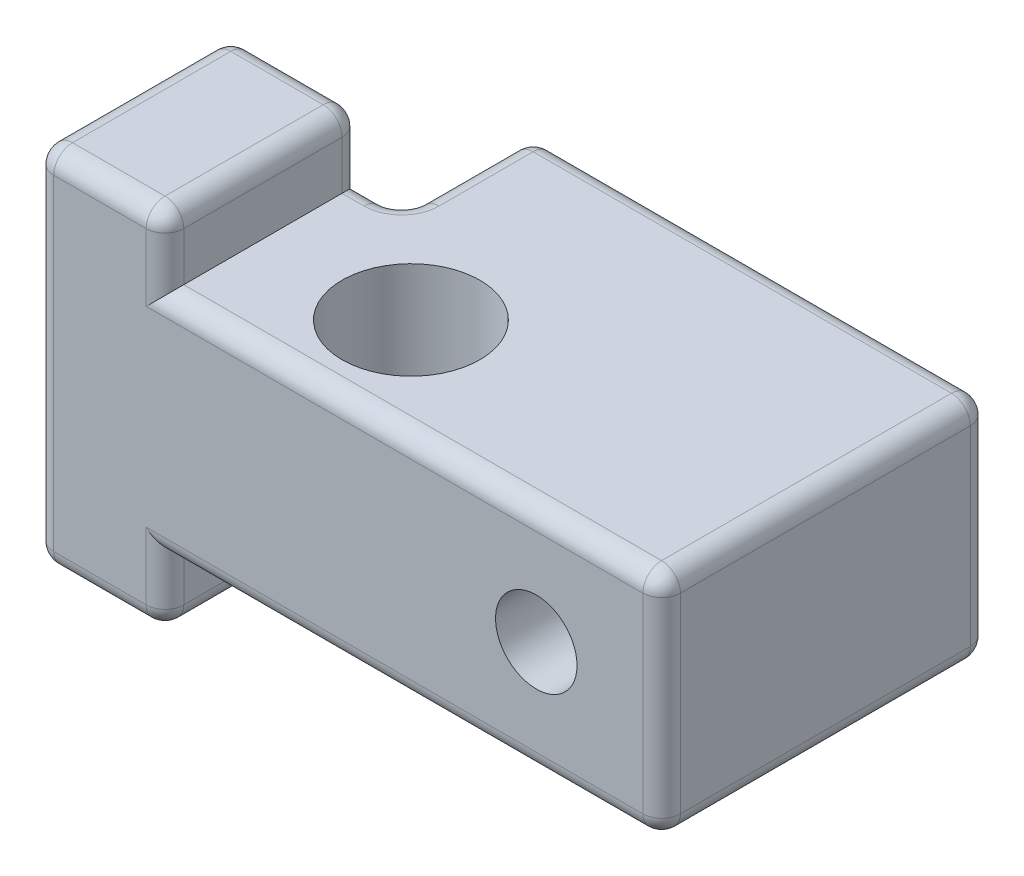
from build123d import *

# Parameters (mm, degrees)
SKETCH1_R                      = 2.794
BOSS_EXTRUDE1_DEPTH            = 4.6355
SKETCH3_W                      = 5.2705
SKETCH3_H                      = 10.4775
BOSS_EXTRUDE3_DEPTH            = 7.366
SKETCH5_R                      = 1.651
CUT_EXTRUDE2_DEPTH             = 15.8115
CUT_EXTRUDE3_REACH             = 4.731
SKETCH6_W                      = 25.4
SKETCH6_H                      = 2.54
CUT_EXTRUDE3_DIRECTION_2_REACH = 14.002
FILLET1_R                      = 0.762


with BuildPart() as part:
    # Sketch1 → Boss-Extrude1 (new body, symmetric)
    with BuildSketch(Plane(origin=(0, 0, 0), x_dir=(1, 0, 0), z_dir=(0, 1, 0))):
        Polygon((-11.1125, 3.81), (-4.191, 3.81), (-4.191, 9.144), (14.2875, 9.144), (14.2875, -6.6675), (-11.1125, -6.6675), align=None)
        Circle(SKETCH1_R, mode=Mode.SUBTRACT)
    extrude(amount=BOSS_EXTRUDE1_DEPTH, both=True)

    # Sketch3 → Boss-Extrude3 (add, symmetric)
    with BuildSketch(Plane(origin=(0, 0, 0), x_dir=(1, 0, 0), z_dir=(0, 1, 0))):
        with Locations((-8.47725, -1.42875)):
            Rectangle(SKETCH3_W, SKETCH3_H)
    extrude(amount=BOSS_EXTRUDE3_DEPTH, both=True)

    # Sketch5 → Cut-Extrude2 (cut)
    with BuildSketch(Plane.XY.offset(6.6675)):
        with Locations((9.2075, 0)):
            Circle(SKETCH5_R)
    extrude(amount=-CUT_EXTRUDE2_DEPTH, mode=Mode.SUBTRACT)

    # Cut-Extrude3: up to this face of the body (flat: up to its plane)
    cut_extrude3_end = Plane(part.part.faces().sort_by_distance((-8.47725, 7.366, 1.42875))[0])
    # Sketch6 → Cut-Extrude3 (cut, up to the picked face)
    with BuildSketch(Plane(origin=(0, 4.6355, 0), x_dir=(1, 0, 0), z_dir=(0, 1, 0)), mode=Mode.PRIVATE) as cut_extrude3_sk1:
        with Locations((1.5875, -5.3975)):
            Rectangle(SKETCH6_W, SKETCH6_H)
    cut_extrude3_tool1 = split(extrude(cut_extrude3_sk1.sketch, amount=CUT_EXTRUDE3_REACH, mode=Mode.PRIVATE), bisect_by=cut_extrude3_end, keep=Keep.BOTH, mode=Mode.PRIVATE)
    add(cut_extrude3_tool1.solids().sort_by_distance((1.5875, 4.6355, 5.3975))[0], mode=Mode.SUBTRACT)

    # Cut-Extrude3 direction 2: up to this face of the body (flat: up to its plane)
    cut_extrude3_direction_2_end = Plane(part.part.faces().sort_by_distance((-8.47725, -7.366, 1.42875))[0])
    # Sketch6 → Cut-Extrude3 direction 2 (cut, up to the picked face)
    with BuildSketch(Plane(origin=(0, 4.6355, 0), x_dir=(1, 0, 0), z_dir=(0, 1, 0)), mode=Mode.PRIVATE) as cut_extrude3_direction_2_sk1:
        with Locations((1.5875, -5.3975)):
            Rectangle(SKETCH6_W, SKETCH6_H)
    cut_extrude3_direction_2_tool1 = split(extrude(cut_extrude3_direction_2_sk1.sketch, amount=-CUT_EXTRUDE3_DIRECTION_2_REACH, mode=Mode.PRIVATE), bisect_by=cut_extrude3_direction_2_end, keep=Keep.BOTH, mode=Mode.PRIVATE)
    add(cut_extrude3_direction_2_tool1.solids().sort_by_distance((1.5875, 4.6355, 5.3975))[0], mode=Mode.SUBTRACT)

    # Fillet1
    fillet1_edges = [part.edges().sort_by_distance(p)[0] for p in [
        (-11.1125, 0, -3.81),
        (-4.191, 0, -3.81),
        (-4.191, 0, -9.144),
        (14.2875, 0, -9.144),
        (5.04825, 4.6355, -9.144),
        (-4.191, 4.6355, -6.477),
        (-5.0165, 4.6355, -3.81),
        (-5.842, 6.00075, -3.81),
        (-5.842, -6.00075, -3.81),
        (-8.47725, -7.366, -3.81),
        (-11.1125, -7.366, 0.15875),
        (-8.47725, 7.366, -3.81),
        (-11.1125, 7.366, 0.15875),
        (-5.842, 7.366, 0.15875),
        (-5.842, -7.366, 0.15875),
        (14.2875, -4.6355, -2.50825),
        (14.2875, 4.6355, -2.50825),
        (-8.47725, -7.366, 4.1275),
        (-8.47725, 7.366, 4.1275),
        (-5.0165, -4.6355, -3.81),
        (-5.842, -6.00075, 4.1275),
        (14.2875, 0, 4.1275),
        (4.22275, -4.6355, 4.1275),
        (4.22275, 4.6355, 4.1275),
        (-5.842, 6.00075, 4.1275),
        (-11.1125, 0, 4.1275),
        (-4.191, -4.6355, -6.477),
        (5.04825, -4.6355, -9.144),
    ]]
    fillet(fillet1_edges, radius=FILLET1_R)


solid = part.part
